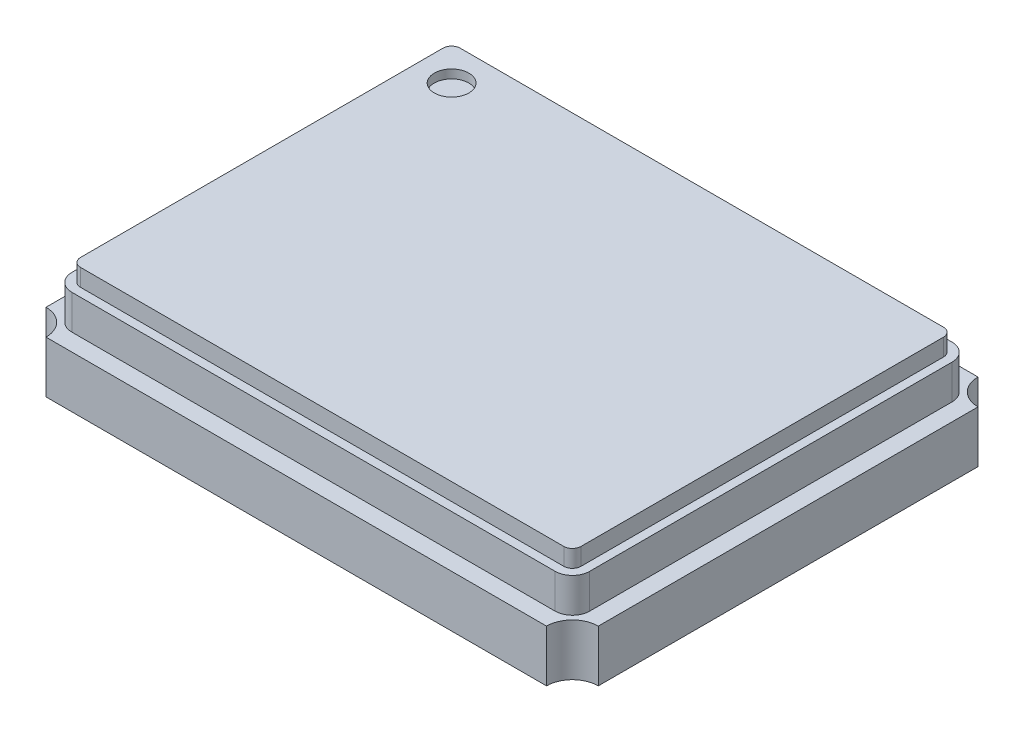
from build123d import *

# Parameters (mm, degrees)
SKETCH1_W           = 3.2
SKETCH1_H           = 2.5
BOSS_EXTRUDE1_DEPTH = 0.3
BOSS_EXTRUDE2_DEPTH = 0.2
BOSS_EXTRUDE3_DEPTH = 0.1
SKETCH4_R           = 0.15
CUT_EXTRUDE1_DEPTH  = 1.3
SKETCH5_R           = 0.1
CUT_EXTRUDE2_DEPTH  = 0.05


with BuildPart() as part:
    # Sketch1 → Boss-Extrude1 (new body)
    with BuildSketch(Plane(origin=(0, 0, 0), x_dir=(1, 0, 0), z_dir=(0, 1, 0))):
        Rectangle(SKETCH1_W, SKETCH1_H)
    extrude(amount=BOSS_EXTRUDE1_DEPTH)

    # Sketch2 → Boss-Extrude2 (add)
    with BuildSketch(Plane(origin=(0, 0.3, 0), x_dir=(1, 0, 0), z_dir=(0, 1, 0))):
        with BuildLine():
            Line((-1.4, -1.15), (1.4, -1.15))
            ThreePointArc((1.4, -1.15), (1.470710678, -1.120710678), (1.5, -1.05))
            Line((1.5, -1.05), (1.5, 1.05))
            ThreePointArc((1.5, 1.05), (1.470710678, 1.120710678), (1.4, 1.15))
            Line((1.4, 1.15), (-1.4, 1.15))
            ThreePointArc((-1.4, 1.15), (-1.470710678, 1.120710678), (-1.5, 1.05))
            Line((-1.5, 1.05), (-1.5, -1.05))
            ThreePointArc((-1.5, -1.05), (-1.470710678, -1.120710678), (-1.4, -1.15))
        make_face()
    extrude(amount=BOSS_EXTRUDE2_DEPTH)

    # Sketch3 → Boss-Extrude3 (add)
    with BuildSketch(Plane(origin=(0, 0.5, 0), x_dir=(1, 0, 0), z_dir=(0, 1, 0))):
        with BuildLine():
            Line((-1.4, -1.1), (1.4, -1.1))
            ThreePointArc((1.4, -1.1), (1.435355339, -1.085355339), (1.45, -1.05))
            Line((1.45, -1.05), (1.45, 1.05))
            ThreePointArc((1.45, 1.05), (1.435355339, 1.085355339), (1.4, 1.1))
            Line((1.4, 1.1), (-1.4, 1.1))
            ThreePointArc((-1.4, 1.1), (-1.435355339, 1.085355339), (-1.45, 1.05))
            Line((-1.45, 1.05), (-1.45, -1.05))
            ThreePointArc((-1.45, -1.05), (-1.435355339, -1.085355339), (-1.4, -1.1))
        make_face()
    extrude(amount=BOSS_EXTRUDE3_DEPTH)

    # Sketch4 → Cut-Extrude1 (cut, through all)
    with BuildSketch(Plane(origin=(0, 0.3, 0), x_dir=(1, 0, 0), z_dir=(0, 1, 0))):
        with Locations((-1.6, 1.25)):
            Circle(SKETCH4_R)
        with Locations((1.6, 1.25)):
            Circle(SKETCH4_R)
        with Locations((1.6, -1.25)):
            Circle(SKETCH4_R)
        with Locations((-1.6, -1.25)):
            Circle(SKETCH4_R)
    extrude(amount=-CUT_EXTRUDE1_DEPTH, mode=Mode.SUBTRACT)

    # Sketch5 → Cut-Extrude2 (cut)
    with BuildSketch(Plane(origin=(0, 0.6, 0), x_dir=(1, 0, 0), z_dir=(0, 1, 0))):
        with Locations((-1.25, 0.9)):
            Circle(SKETCH5_R)
    extrude(amount=-CUT_EXTRUDE2_DEPTH, mode=Mode.SUBTRACT)


solid = part.part
